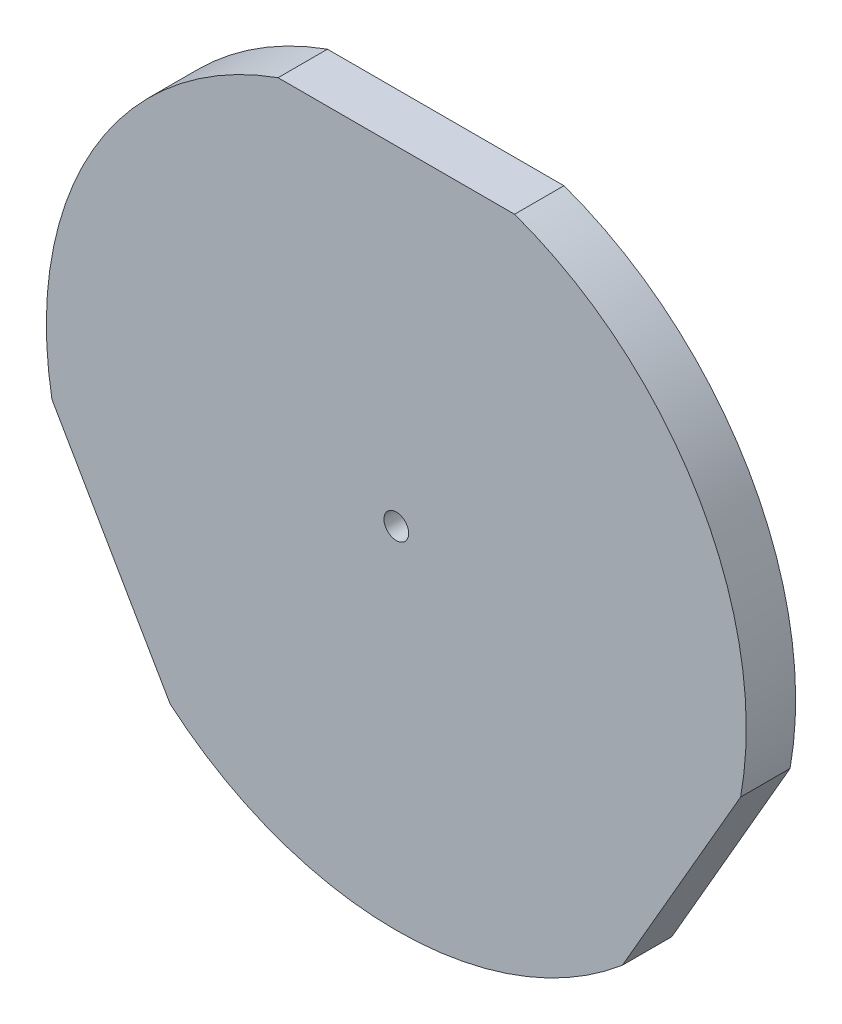
from build123d import *

# Parameters (mm, degrees)
SKETCH1_R           = 85
SKETCH1_R_2         = 3
BOSS_EXTRUDE1_DEPTH = 12
CUT_EXTRUDE1_DEPTH  = 12
CIRPATTERN1_COUNT   = 3


with BuildPart() as part:
    # Sketch1 → Boss-Extrude1 (new body)
    with BuildSketch(Plane.XY):
        Circle(SKETCH1_R)
        Circle(SKETCH1_R_2, mode=Mode.SUBTRACT)
    extrude(amount=BOSS_EXTRUDE1_DEPTH)

    # Sketch2 → Cut-Extrude1 (cut)
    with BuildSketch(Plane.XY.offset(12)):
        with BuildLine():
            Line((-28.722813233, 80), (28.722813233, 80))
            ThreePointArc((28.722813233, 80), (0, 85), (-28.722813233, 80))
        make_face()
    cut_extrude1 = extrude(amount=-CUT_EXTRUDE1_DEPTH, mode=Mode.SUBTRACT)

    # CirPattern1: Cut-Extrude1 ×3 about axis
    cirpattern1_axis = Axis((0, 0, 0), (0, 0, 1))
    for i in range(1, CIRPATTERN1_COUNT):
        add(cut_extrude1.rotate(cirpattern1_axis, i * 360 / CIRPATTERN1_COUNT), mode=Mode.SUBTRACT)


solid = part.part
